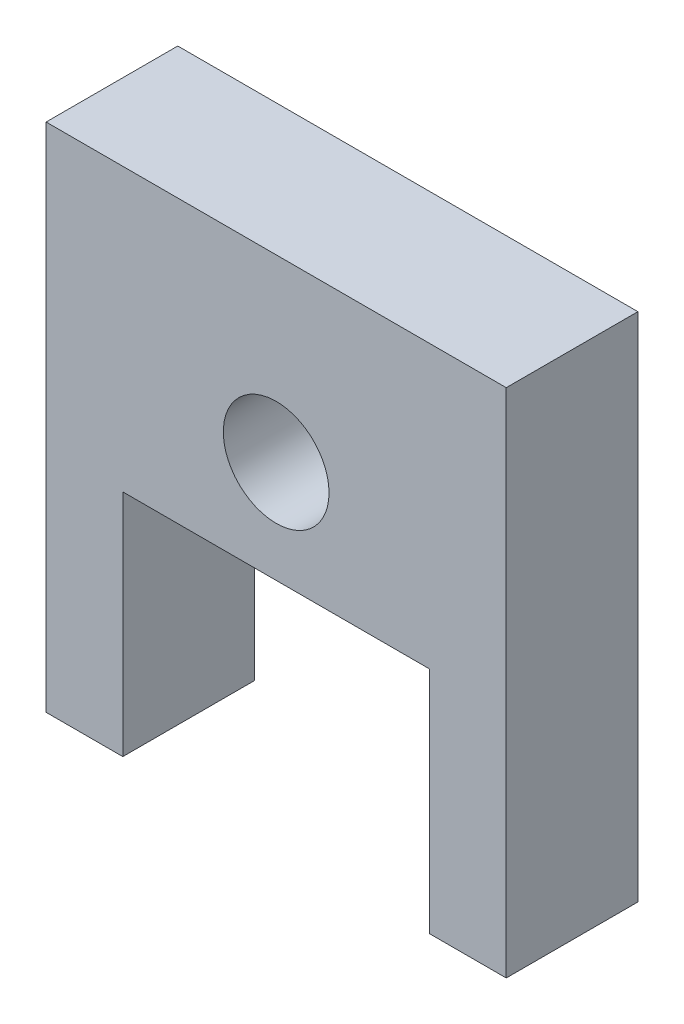
from build123d import *

# Parameters (mm, degrees)
BOSS_EXTRUDE1_DEPTH = 5.15
SKETCH3_R           = 2.0675
CUT_EXTRUDE1_DEPTH  = 6.15


with BuildPart() as part:
    # Sketch1 → Boss-Extrude1 (new body)
    with BuildSketch(Plane.XY):
        Polygon((0, 0), (3, 0), (3, 8.97), (15, 8.97), (15, 0), (18, 0), (18, 20), (0, 20), align=None)
    extrude(amount=BOSS_EXTRUDE1_DEPTH)

    # Sketch3 → Cut-Extrude1 (cut, through all)
    with BuildSketch(Plane.XY.offset(5.15)):
        with Locations((9, 12.97)):
            Circle(SKETCH3_R)
    extrude(amount=-CUT_EXTRUDE1_DEPTH, mode=Mode.SUBTRACT)


solid = part.part
